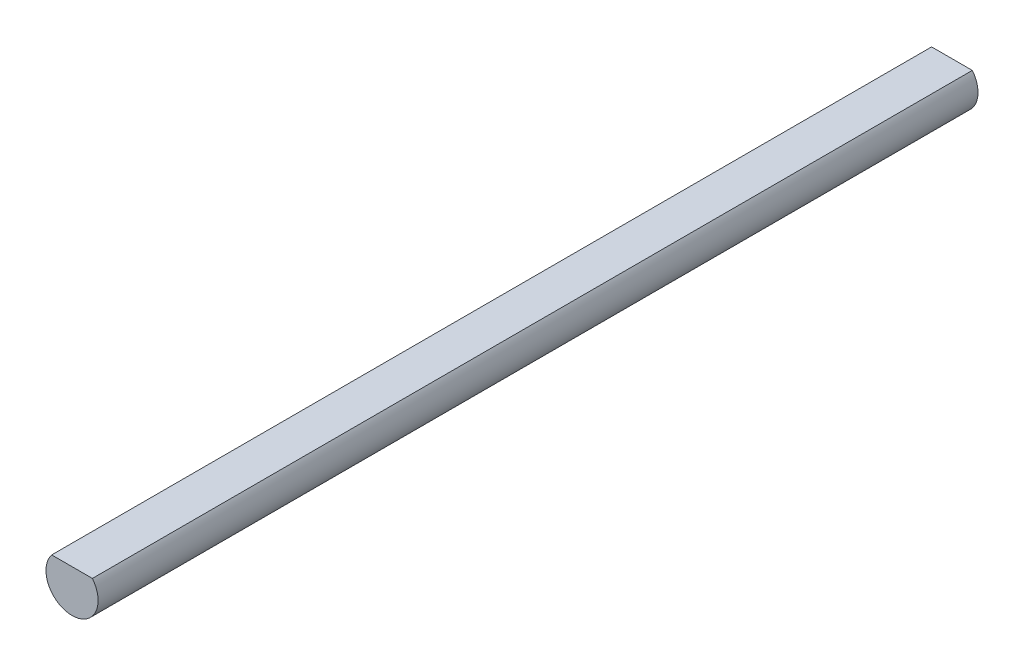
from build123d import *

# Parameters (mm, degrees)
SKETCH2_R               = 4
BOSS_EXTRUDE1_DEPTH     = 135
CUT_EXTRUDE1_DEPTH      = 136
CUT_EXTRUDE1_DEPTH_BACK = 1


with BuildPart() as part:
    # Sketch2 → Boss-Extrude1 (new body)
    with BuildSketch(Plane.XY):
        Circle(SKETCH2_R)
    extrude(amount=BOSS_EXTRUDE1_DEPTH)

    # Sketch3 → Cut-Extrude1 (cut, two sides)
    with BuildSketch(Plane.XY) as cut_extrude1_sk:
        with BuildLine():
            Line((-3.122498999, 2.5), (3.122498999, 2.5))
            ThreePointArc((3.122498999, 2.5), (0, 4), (-3.122498999, 2.5))
        make_face()
    extrude(amount=CUT_EXTRUDE1_DEPTH, mode=Mode.SUBTRACT)
    extrude(cut_extrude1_sk.sketch, amount=-CUT_EXTRUDE1_DEPTH_BACK, mode=Mode.SUBTRACT)


solid = part.part
